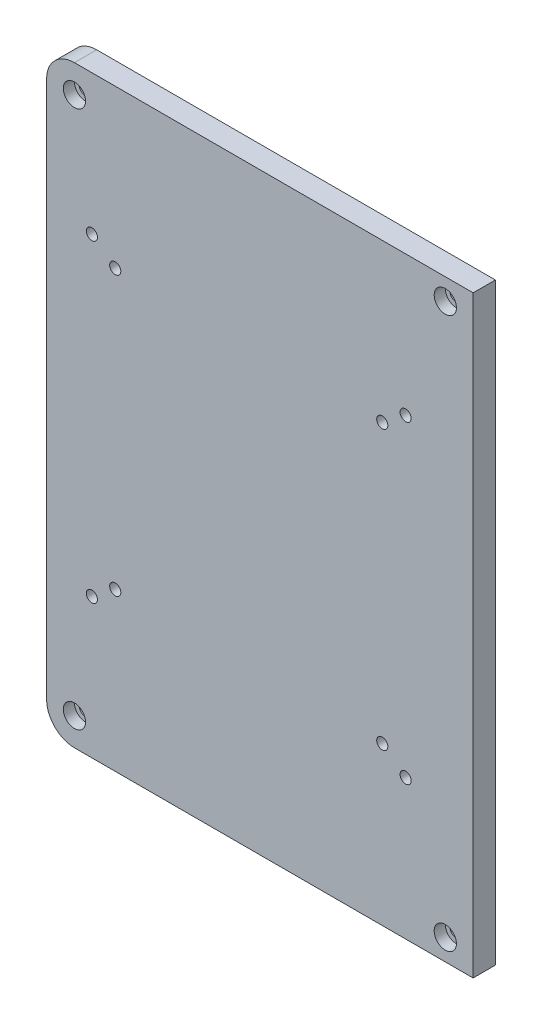
from build123d import *

# Parameters (mm, degrees)
BOSS_EXTRUDE1_DEPTH     = 6
SKETCH2_R               = 1.75
CUT_EXTRUDE1_DEPTH      = 10
SKETCH4_R               = 1.5
CUT_EXTRUDE3_DEPTH      = 7
SKETCH5_R               = 1.375
CUT_EXTRUDE4_DEPTH      = 1
CUT_EXTRUDE4_DEPTH_BACK = 7
SKETCH7_R               = 1.5
CUT_EXTRUDE6_DEPTH      = 7
SKETCH9_W               = 115
SKETCH9_H               = 160
CUT_EXTRUDE8_DEPTH      = 10
SKETCH10_R              = 1.75
CUT_EXTRUDE9_DEPTH      = 6
SKETCH16_R              = 1.75
CUT_EXTRUDE11_DEPTH     = 6
SKETCH19_R              = 3
CUT_EXTRUDE13_DEPTH     = 3


with BuildPart() as part:
    # Sketch1 → Boss-Extrude1 (new body)
    with BuildSketch(Plane.XY):
        with BuildLine():
            Line((-107.5, 80), (107.5, 80))
            ThreePointArc((107.5, 80), (112.803300859, 77.803300859), (115, 72.5))
            Line((115, 72.5), (115, -72.5))
            ThreePointArc((115, -72.5), (112.803300859, -77.803300859), (107.5, -80))
            Line((107.5, -80), (-107.5, -80))
            ThreePointArc((-107.5, -80), (-112.803300859, -77.803300859), (-115, -72.5))
            Line((-115, -72.5), (-115, 72.5))
            ThreePointArc((-115, 72.5), (-112.803300859, 77.803300859), (-107.5, 80))
        make_face()
    extrude(amount=BOSS_EXTRUDE1_DEPTH)

    # Sketch2 → Cut-Extrude1 (cut)
    with BuildSketch(Plane.XY.offset(6)):
        with Locations((-107.5, -72.5)):
            Circle(SKETCH2_R)
        with Locations((-107.5, 72.5)):
            Circle(SKETCH2_R)
        with Locations((107.5, -72.5)):
            Circle(SKETCH2_R)
        with Locations((107.5, 72.5)):
            Circle(SKETCH2_R)
    extrude(amount=-CUT_EXTRUDE1_DEPTH, mode=Mode.SUBTRACT)

    # Sketch4 → Cut-Extrude3 (cut, through all)
    with BuildSketch(Plane.XY.offset(6)):
        with Locations((-96.5, 37.5)):
            Circle(SKETCH4_R)
        with Locations((-96.5, -37.5)):
            Circle(SKETCH4_R)
        with Locations((-24.5, 37.5)):
            Circle(SKETCH4_R)
        with Locations((-24.5, -37.5)):
            Circle(SKETCH4_R)
    extrude(amount=-CUT_EXTRUDE3_DEPTH, mode=Mode.SUBTRACT)

    # Sketch5 → Cut-Extrude4 (cut, two sides)
    with BuildSketch(Plane.XY.offset(6)) as cut_extrude4_sk:
        with Locations((95, -62.5)):
            Circle(SKETCH5_R)
        with Locations((95, 62.5)):
            Circle(SKETCH5_R)
        with Locations((41.7, -62.5)):
            Circle(SKETCH5_R)
        with Locations((41.7, 62.5)):
            Circle(SKETCH5_R)
    extrude(amount=CUT_EXTRUDE4_DEPTH, mode=Mode.SUBTRACT)
    extrude(cut_extrude4_sk.sketch, amount=-CUT_EXTRUDE4_DEPTH_BACK, mode=Mode.SUBTRACT)

    # Sketch7 → Cut-Extrude6 (cut, through all)
    with BuildSketch(Plane.XY.offset(6)):
        with Locations((-102.8, 42.3)):
            Circle(SKETCH7_R)
        with Locations((-102.8, -42.3)):
            Circle(SKETCH7_R)
        with Locations((-18.2, -42.3)):
            Circle(SKETCH7_R)
        with Locations((-18.2, 42.3)):
            Circle(SKETCH7_R)
    extrude(amount=-CUT_EXTRUDE6_DEPTH, mode=Mode.SUBTRACT)

    # Sketch9 → Cut-Extrude8 (cut)
    with BuildSketch(Plane.XY.offset(6)):
        with Locations((57.5, 0)):
            Rectangle(SKETCH9_W, SKETCH9_H)
    extrude(amount=-CUT_EXTRUDE8_DEPTH, mode=Mode.SUBTRACT)

    # Sketch10 → Cut-Extrude9 (cut)
    with BuildSketch(Plane.XY.offset(6)):
        with Locations((-7.5, -74.25)):
            Circle(SKETCH10_R)
    extrude(amount=-CUT_EXTRUDE9_DEPTH, mode=Mode.SUBTRACT)

    # Sketch16 → Cut-Extrude11 (cut)
    with BuildSketch(Plane.XY.offset(6)):
        with Locations((-7.5, 74.25)):
            Circle(SKETCH16_R)
    extrude(amount=-CUT_EXTRUDE11_DEPTH, mode=Mode.SUBTRACT)

    # Sketch19 → Cut-Extrude13 (cut)
    with BuildSketch(Plane.XY.offset(6)):
        with Locations((-107.5, -72.5)):
            Circle(SKETCH19_R)
        with Locations((-7.5, -74.25)):
            Circle(SKETCH19_R)
        with Locations((-7.5, 74.25)):
            Circle(SKETCH19_R)
        with Locations((-107.5, 72.5)):
            Circle(SKETCH19_R)
    extrude(amount=-CUT_EXTRUDE13_DEPTH, mode=Mode.SUBTRACT)


solid = part.part
